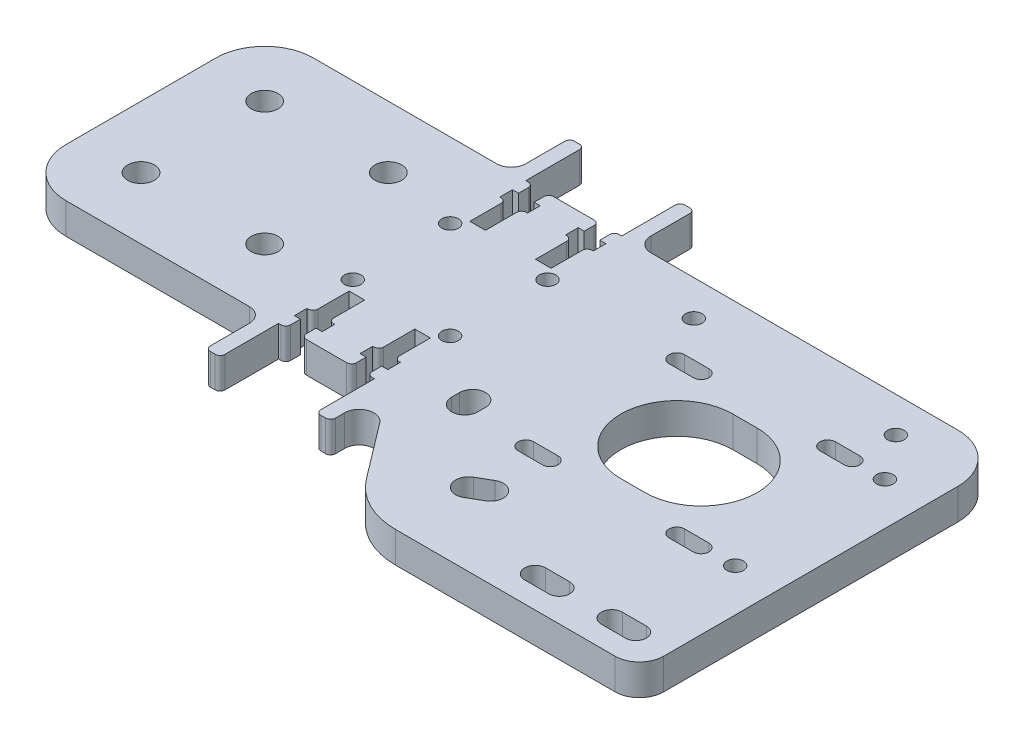
from build123d import *

# Parameters (mm, degrees)
BOSS_EXTRUDE1_DEPTH  = 6.35
M5_CLEARANCE_HOLE1_D = 5.5
M3_CLEARANCE_HOLE1_D = 3.4
CUT_EXTRUDE1_DEPTH   = 7.35
CUT_EXTRUDE2_DEPTH   = 7.35
FILLET1_R            = 10
CUT_EXTRUDE3_DEPTH   = 7.35
M3_CLEARANCE_HOLE2_D = 3.4
FILLET3_R            = 5
SKETCH13_W           = 3
SKETCH13_H           = 12
BOSS_EXTRUDE2_DEPTH  = 6.35
FILLET4_R            = 3
CUT_EXTRUDE4_DEPTH   = 7.35
FILLET5_R            = 1
FILLET6_R            = 1


with BuildPart() as part:
    # Sketch1 → Boss-Extrude1 (new body)
    with BuildSketch(Plane(origin=(0, 0, 0), x_dir=(1, 0, 0), z_dir=(0, 1, 0))):
        with BuildLine():
            Line((38.1, -25.4), (-38.1, -25.4))
            Line((-38.1, -25.4), (-38.1, 25.4))
            Line((-38.1, 25.4), (38.1, 25.4))
            Line((38.1, 25.4), (114.321209859, 25.4))
            Line((114.321209859, 25.4), (114.321209859, -50.04))
            Line((114.321209859, -50.04), (64.241941751, -50.04))
            ThreePointArc((64.241941751, -50.04), (57.570841587, -48.474895705), (52.291870426, -44.10618968))
            Line((52.291870426, -44.10618968), (38.1, -25.4))
        make_face()
    extrude(amount=BOSS_EXTRUDE1_DEPTH)

    # M5 Clearance Hole1 (through all)
    with Locations(Plane(origin=(0, 6.35, 0), x_dir=(1, 0, 0), z_dir=(0, 1, 0))):
        with Locations((-25.4, 12.7), (0, 12.7), (0, -12.7), (-25.4, -12.7)):
            Hole(M5_CLEARANCE_HOLE1_D / 2)

    # M3 Clearance Hole1 (through all)
    with Locations(Plane(origin=(0, 6.35, 0), x_dir=(1, 0, 0), z_dir=(0, 1, 0))):
        with Locations((15.4, 10), (35.4, 10), (35.4, -10), (15.4, -10)):
            Hole(M3_CLEARANCE_HOLE1_D / 2)

    # Sketch6 → Cut-Extrude1 (cut, through all)
    with BuildSketch(Plane(origin=(0, 6.35, 0), x_dir=(1, 0, 0), z_dir=(0, 1, 0))):
        with BuildLine():
            Line((62.821209859, 7.54), (67.821209859, 7.54))
            ThreePointArc((67.821209859, 7.54), (69.421209859, 9.14), (67.821209859, 10.74))
            Line((67.821209859, 10.74), (62.821209859, 10.74))
            ThreePointArc((62.821209859, 10.74), (61.221209859, 9.14), (62.821209859, 7.54))
        make_face()
        with BuildLine():
            Line((62.821209859, -23.46), (67.821209859, -23.46))
            ThreePointArc((67.821209859, -23.46), (69.421209859, -21.86), (67.821209859, -20.26))
            Line((67.821209859, -20.26), (62.821209859, -20.26))
            ThreePointArc((62.821209859, -20.26), (61.221209859, -21.86), (62.821209859, -23.46))
        make_face()
        with BuildLine():
            Line((93.821209859, -23.46), (98.821209859, -23.46))
            ThreePointArc((98.821209859, -23.46), (100.421209859, -21.86), (98.821209859, -20.26))
            Line((98.821209859, -20.26), (93.821209859, -20.26))
            ThreePointArc((93.821209859, -20.26), (92.221209859, -21.86), (93.821209859, -23.46))
        make_face()
        with BuildLine():
            Line((93.821209859, 7.54), (98.821209859, 7.54))
            ThreePointArc((98.821209859, 7.54), (100.421209859, 9.14), (98.821209859, 10.74))
            Line((98.821209859, 10.74), (93.821209859, 10.74))
            ThreePointArc((93.821209859, 10.74), (92.221209859, 9.14), (93.821209859, 7.54))
        make_face()
        with BuildLine():
            Line((78.321209859, -17.86), (83.321209859, -17.86))
            ThreePointArc((83.321209859, -17.86), (94.821209859, -6.36), (83.321209859, 5.14))
            Line((83.321209859, 5.14), (78.321209859, 5.14))
            ThreePointArc((78.321209859, 5.14), (66.821209859, -6.36), (78.321209859, -17.86))
        make_face()
    extrude(amount=-CUT_EXTRUDE1_DEPTH, mode=Mode.SUBTRACT)

    # Sketch7 → Cut-Extrude2 (cut, through all)
    with BuildSketch(Plane(origin=(0, 6.35, 0), x_dir=(1, 0, 0), z_dir=(0, 1, 0))):
        with BuildLine():
            Line((65.751764766, -31.105892862), (62.915452987, -32.745892862))
            ThreePointArc((62.915452987, -32.745892862), (61.947834614, -36.366488764), (65.568430515, -37.334107138))
            Line((65.568430515, -37.334107138), (68.404742294, -35.694107138))
            ThreePointArc((68.404742294, -35.694107138), (69.372360668, -32.073511236), (65.751764766, -31.105892862))
        make_face()
        with BuildLine():
            Line((46.45, -19.08), (46.45, -20.72))
            ThreePointArc((46.45, -20.72), (49.1, -23.37), (51.75, -20.72))
            Line((51.75, -20.72), (51.75, -19.08))
            ThreePointArc((51.75, -19.08), (49.1, -16.43), (46.45, -19.08))
        make_face()
    extrude(amount=-CUT_EXTRUDE2_DEPTH, mode=Mode.SUBTRACT)

    # Fillet1
    fillet1_edges = [part.edges().sort_by_distance(p)[0] for p in [
        (-38.1, 3.175, -25.4),
        (114.321209859, 3.175, -25.4),
        (-38.1, 3.175, 25.4),
    ]]
    fillet(fillet1_edges, radius=FILLET1_R)

    # Sketch8 → Cut-Extrude3 (cut, through all)
    with BuildSketch(Plane(origin=(0, 6.35, 0), x_dir=(1, 0, 0), z_dir=(0, 1, 0))):
        with BuildLine():
            Line((107.171209859, -41.46), (102.221209859, -41.46))
            ThreePointArc((102.221209859, -41.46), (100.071209859, -43.61), (102.221209859, -45.76))
            Line((102.221209859, -45.76), (107.171209859, -45.76))
            ThreePointArc((107.171209859, -45.76), (109.321209859, -43.61), (107.171209859, -41.46))
        make_face()
        with BuildLine():
            Line((86.471209859, -45.76), (91.421209859, -45.76))
            ThreePointArc((91.421209859, -45.76), (93.571209859, -43.61), (91.421209859, -41.46))
            Line((91.421209859, -41.46), (86.471209859, -41.46))
            ThreePointArc((86.471209859, -41.46), (84.321209859, -43.61), (86.471209859, -45.76))
        make_face()
    extrude(amount=-CUT_EXTRUDE3_DEPTH, mode=Mode.SUBTRACT)

    # M3 Clearance Hole2 (through all)
    with Locations(Plane(origin=(0, 6.35, 0), x_dir=(1, 0, 0), z_dir=(0, 1, 0))):
        with Locations((57.321209859, 18.14), (98.821209859, 18.14), (105.566578641, 9.14), (105.566578641, -21.61)):
            Hole(M3_CLEARANCE_HOLE2_D / 2)

    # Fillet3
    fillet3_edges = [part.edges().sort_by_distance(p)[0] for p in [
        (114.321209859, 3.175, 50.04),
    ]]
    fillet(fillet3_edges, radius=FILLET3_R)

    # Sketch13 → Boss-Extrude2 (add)
    with BuildSketch(Plane(origin=(0, 6.35, 0), x_dir=(1, 0, 0), z_dir=(0, 1, 0))):
        with Locations((36.75, 31.4)):
            Rectangle(SKETCH13_W, SKETCH13_H)
        with Locations((14.05, 31.4)):
            Rectangle(SKETCH13_W, SKETCH13_H)
        with Locations((14.05, -31.4)):
            Rectangle(SKETCH13_W, SKETCH13_H)
        with Locations((36.75, -31.4)):
            Rectangle(SKETCH13_W, SKETCH13_H)
    extrude(amount=-BOSS_EXTRUDE2_DEPTH)

    # Fillet4
    fillet4_edges = [part.edges().sort_by_distance(p)[0] for p in [
        (38.25, 3.175, -25.4),
        (12.55, 3.175, -25.4),
        (12.55, 3.175, 25.4),
        (38.25, 3.175, 25.597713787),
    ]]
    fillet(fillet4_edges, radius=FILLET4_R)

    # Sketch14 → Cut-Extrude4 (cut, through all)
    with BuildSketch(Plane(origin=(0, 6.35, 0), x_dir=(1, 0, 0), z_dir=(0, 1, 0))):
        Polygon((17.05, 12.4), (20.25, 12.4), (20.25, 19.8), (21.5, 19.8), (21.5, 22.4), (20.25, 22.4), (20.25, 25.4), (17.05, 25.4), (17.05, 22.4), (15.8, 22.4), (15.8, 19.8), (17.05, 19.8), align=None)
        Polygon((35, 22.4), (33.75, 22.4), (33.75, 25.4), (30.55, 25.4), (30.55, 22.4), (29.3, 22.4), (29.3, 19.8), (30.55, 19.8), (30.55, 12.4), (33.75, 12.4), (33.75, 19.8), (35, 19.8), align=None)
        Polygon((21.5, -22.4), (20.25, -22.4), (20.25, -25.4), (17.05, -25.4), (17.05, -22.4), (15.8, -22.4), (15.8, -19.8), (17.05, -19.8), (17.05, -12.4), (20.25, -12.4), (20.25, -19.8), (21.5, -19.8), align=None)
        Polygon((30.55, -19.8), (29.3, -19.8), (29.3, -22.4), (30.55, -22.4), (30.55, -25.4), (33.75, -25.4), (33.75, -22.4), (35, -22.4), (35, -19.8), (33.75, -19.8), (33.75, -12.4), (30.55, -12.4), align=None)
    extrude(amount=-CUT_EXTRUDE4_DEPTH, mode=Mode.SUBTRACT)

    # Fillet5
    fillet5_edges = [part.edges().sort_by_distance(p)[0] for p in [
        (35.25, 3.175, -37.4),
        (38.25, 3.175, -37.4),
        (12.55, 3.175, -37.4),
        (15.55, 3.175, -37.4),
        (15.55, 3.175, 37.4),
        (12.55, 3.175, 37.4),
        (38.25, 3.175, 37.4),
        (35.25, 3.175, 37.4),
        (20.25, 3.175, 25.4),
        (17.05, 3.175, 25.4),
        (17.05, 3.175, 19.8),
        (20.25, 3.175, 19.8),
        (30.55, 3.175, 19.8),
        (33.75, 3.175, 19.8),
        (33.75, 3.175, 25.4),
        (30.55, 3.175, 25.4),
    ]]
    fillet(fillet5_edges, radius=FILLET5_R)

    # Fillet6
    fillet6_edges = [part.edges().sort_by_distance(p)[0] for p in [
        (20.25, 3.175, -19.8),
        (17.05, 3.175, -19.8),
        (17.05, 3.175, -25.4),
        (20.25, 3.175, -25.4),
        (33.75, 3.175, -19.8),
        (30.55, 3.175, -19.8),
        (30.55, 3.175, -25.4),
        (33.75, 3.175, -25.4),
    ]]
    fillet(fillet6_edges, radius=FILLET6_R)


solid = part.part
